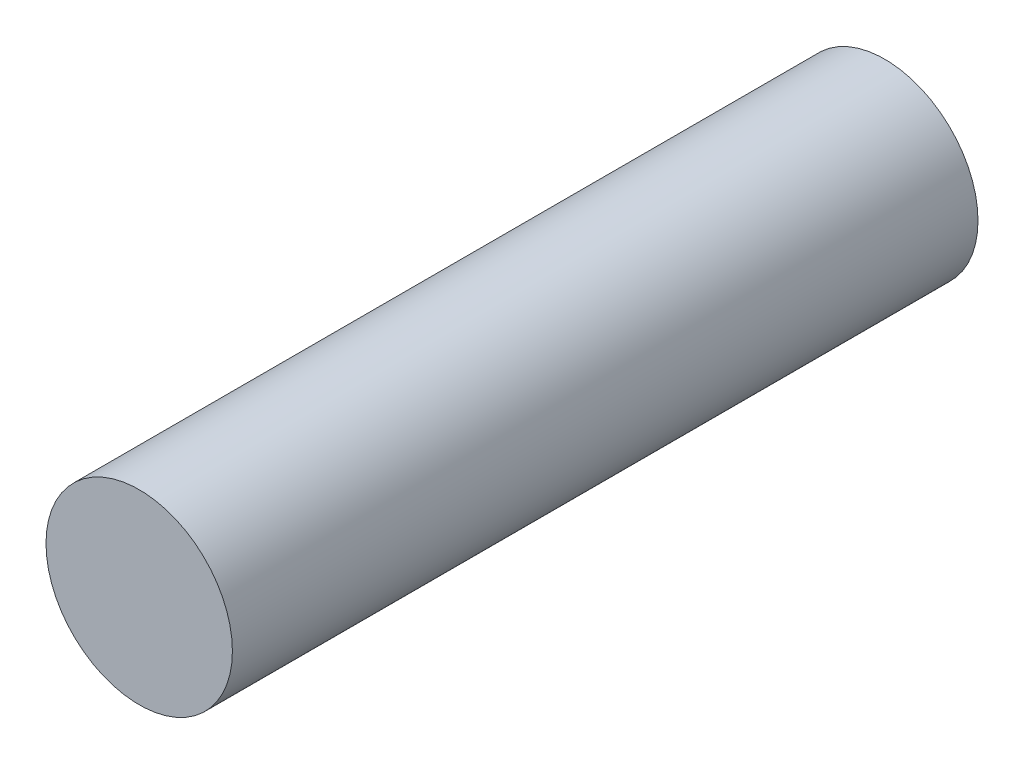
from build123d import *

# Parameters (mm, degrees)
ESQUISSE1_R      = 5
EXTRUSION1_DEPTH = 40


with BuildPart() as part:
    # Esquisse1 → Extrusion1 (new body)
    with BuildSketch(Plane.XY):
        Circle(ESQUISSE1_R)
    extrude(amount=EXTRUSION1_DEPTH)


solid = part.part
